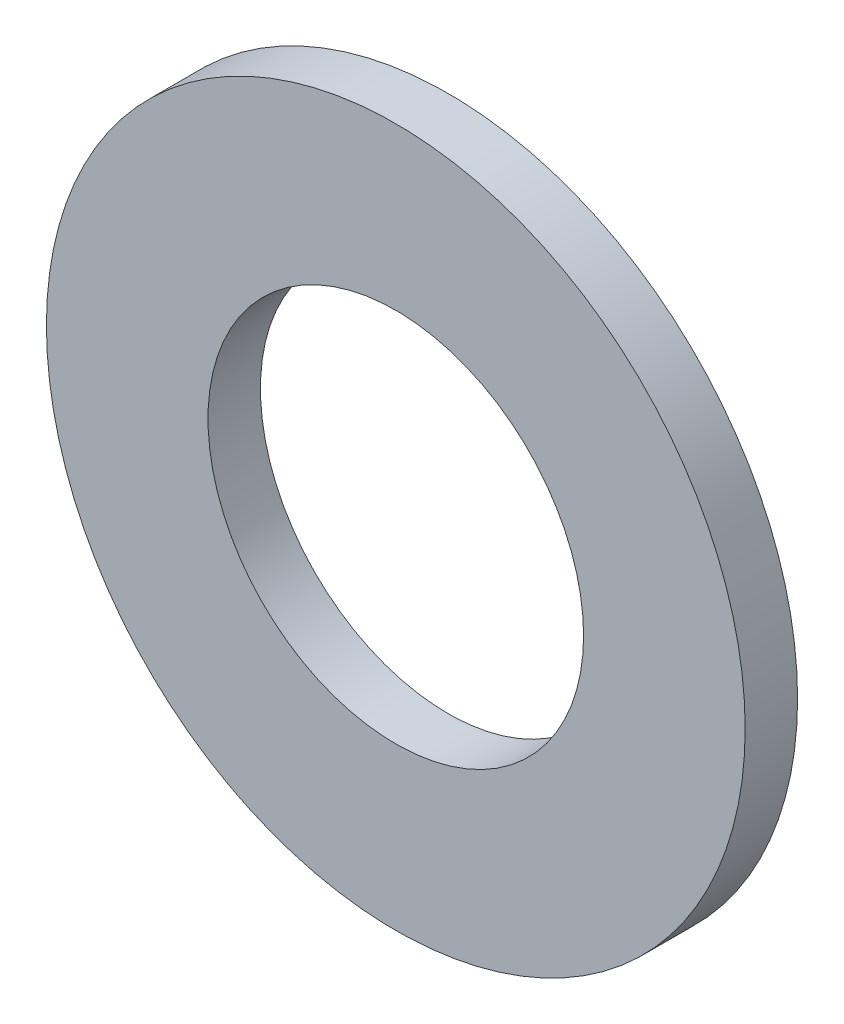
from build123d import *

# Parameters (mm, degrees)
SKETCH1_R           = 4
SKETCH1_R_2         = 2.15
BOSS_EXTRUDE1_DEPTH = 0.6


with BuildPart() as part:
    # Sketch1 → Boss-Extrude1 (new body)
    with BuildSketch(Plane.XY):
        Circle(SKETCH1_R)
        Circle(SKETCH1_R_2, mode=Mode.SUBTRACT)
    extrude(amount=BOSS_EXTRUDE1_DEPTH)


solid = part.part
